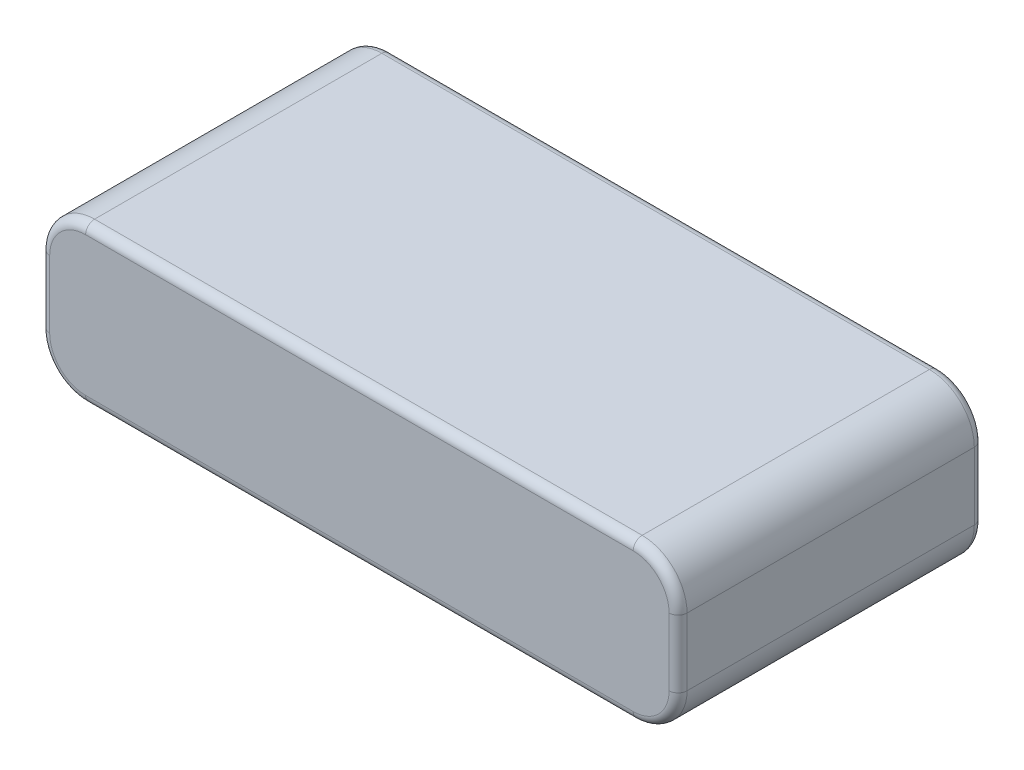
from build123d import *

# Parameters (mm, degrees)
SKETCH1_W           = 71
SKETCH1_H           = 34
BOSS_EXTRUDE1_DEPTH = 17.5
FILLET1_R           = 5
FILLET2_R           = 1


with BuildPart() as part:
    # Sketch1 → Boss-Extrude1 (new body)
    with BuildSketch(Plane(origin=(0, 0, 0), x_dir=(1, 0, 0), z_dir=(0, 1, 0))):
        Rectangle(SKETCH1_W, SKETCH1_H)
    extrude(amount=BOSS_EXTRUDE1_DEPTH)

    # Fillet1
    fillet1_edges = [part.edges().sort_by_distance(p)[0] for p in [
        (-35.5, 17.5, 0),
        (35.5, 17.5, 0),
        (-35.5, 0, 0),
        (35.5, 0, 0),
    ]]
    fillet(fillet1_edges, radius=FILLET1_R)

    # Fillet2
    fillet2_edges = [part.edges().sort_by_distance(p)[0] for p in [
        (-35.5, 8.75, 17),
        (-35.5, 8.75, -17),
        (0, 0, 17),
        (35.5, 8.75, 17),
        (0, 17.5, 17),
        (-34.035533906, 16.035533906, 17),
        (34.035533906, 16.035533906, 17),
        (34.035533906, 1.464466094, 17),
        (-34.035533906, 1.464466094, 17),
        (0, 0, -17),
        (0, 17.5, -17),
        (35.5, 8.75, -17),
        (-34.035533906, 16.035533906, -17),
        (34.035533906, 16.035533906, -17),
        (34.035533906, 1.464466094, -17),
        (-34.035533906, 1.464466094, -17),
    ]]
    fillet(fillet2_edges, radius=FILLET2_R)


solid = part.part
